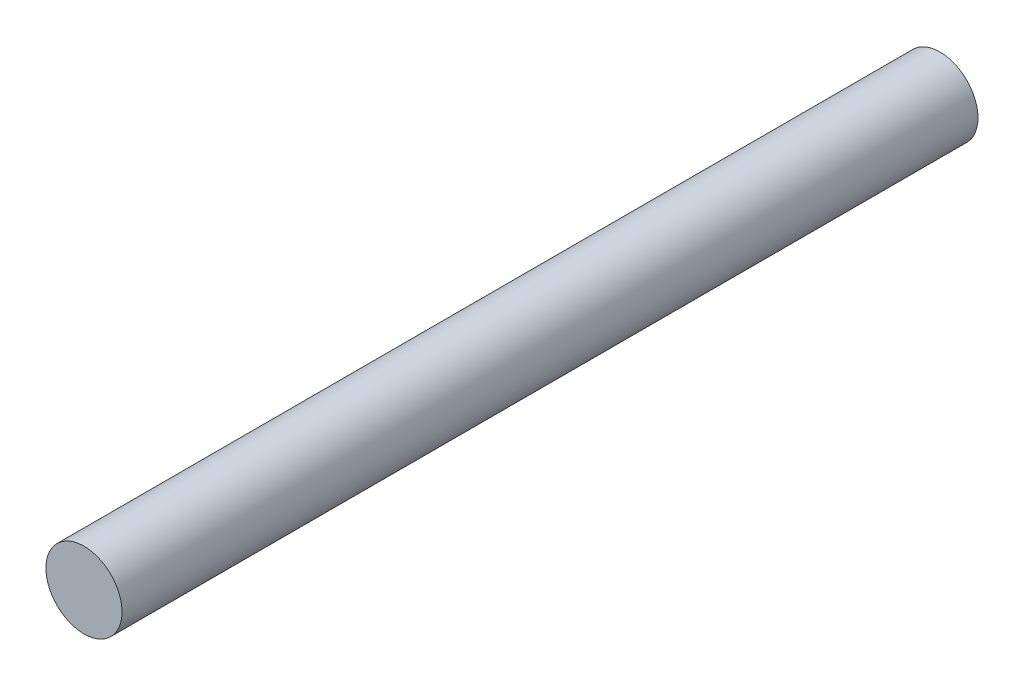
from build123d import *

# Parameters (mm, degrees)
SKETCH1_R           = 20
BOSS_EXTRUDE1_DEPTH = 450


with BuildPart() as part:
    # Sketch1 → Boss-Extrude1 (new body)
    with BuildSketch(Plane.XY):
        Circle(SKETCH1_R)
    extrude(amount=BOSS_EXTRUDE1_DEPTH)


solid = part.part
